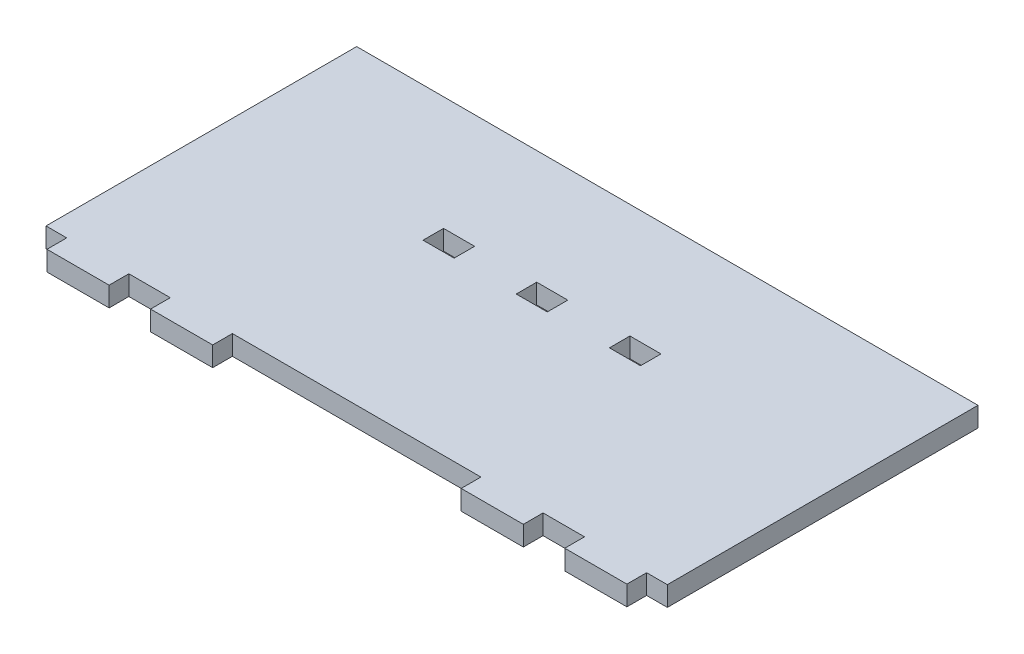
from build123d import *

# Parameters (mm, degrees)
BOSS_EXTRUDE1_DEPTH = 3.175
SKETCH2_W           = 5
SKETCH2_H           = 3.3
CUT_EXTRUDE1_DEPTH  = 3.175


with BuildPart() as part:
    # Sketch1 → Boss-Extrude1 (new body)
    with BuildSketch(Plane(origin=(0, 0, 0), x_dir=(1, 0, 0), z_dir=(0, 1, 0))):
        Polygon((-50, 25), (50, 25), (50, -25), (46.666666667, -25), (46.666666667, -28.175), (36.666666667, -28.175), (36.666666667, -25), (30, -25), (30, -28.175), (20, -28.175), (20, -25), (-20, -25), (-20, -28.175), (-30, -28.175), (-30, -25), (-36.666666667, -25), (-36.666666667, -28.175), (-46.666666667, -28.175), (-46.666666667, -25), (-50, -25), align=None)
    extrude(amount=BOSS_EXTRUDE1_DEPTH)

    # Sketch2 → Cut-Extrude1 (cut)
    with BuildSketch(Plane(origin=(0, 3.175, 0), x_dir=(1, 0, 0), z_dir=(0, 1, 0))):
        with Locations((-0.169597497, 5)):
            Rectangle(SKETCH2_W, SKETCH2_H)
        with Locations((-15.169597497, 5)):
            Rectangle(SKETCH2_W, SKETCH2_H)
        with Locations((14.830402503, 5)):
            Rectangle(SKETCH2_W, SKETCH2_H)
    extrude(amount=-CUT_EXTRUDE1_DEPTH, mode=Mode.SUBTRACT)


solid = part.part
